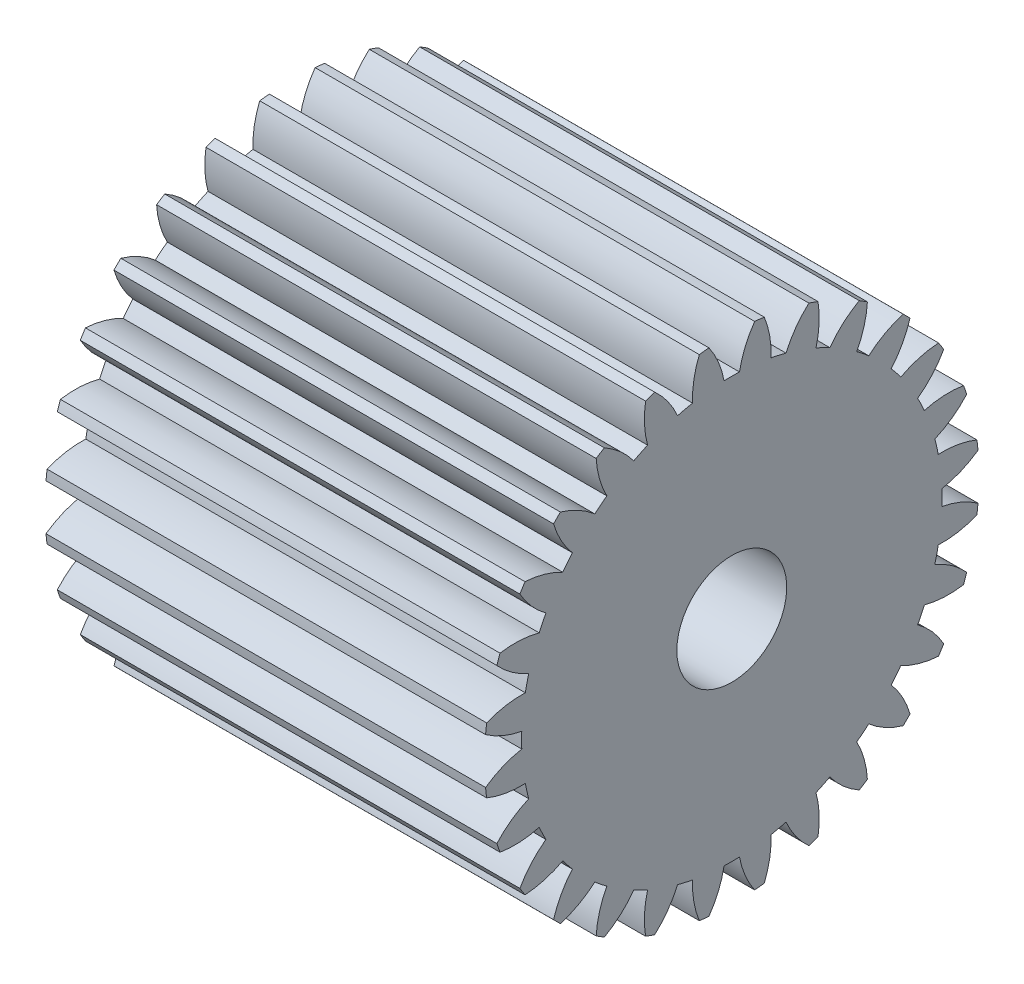
from build123d import *

# Parameters (mm, degrees)
BASPROSKE_W     = 40
BASPROSKE_H     = 22.5
TOOTHCUT_DEPTH  = 52.112620751
TEETHCUTS_COUNT = 28
TEETHCUTS_ANGLE = 347.142857143
BORSKE_R        = 5
BORE_DEPTH      = 50.0000508
SCALE1_SCALE    = 2


with BuildPart() as part:
    # BasProSke → Base-Revolve (revolve)
    with BuildSketch(Plane(origin=(0, 0, 0), x_dir=(1, 0, 0), z_dir=(0, 1, 0)), mode=Mode.PRIVATE) as base_revolve_sk:
        with Locations((20, 11.25)):
            Rectangle(BASPROSKE_W, BASPROSKE_H)
    revolve(base_revolve_sk.sketch.rotate(Axis((-10, 0, 0), (1, 0, 0)), 180), axis=Axis((-10, 0, 0), (1, 0, 0)))

    # TooCutSke → ToothCut (cut, through all)
    with BuildSketch(Plane(origin=(0, 0, 0), x_dir=(0, 0, -1), z_dir=(1, 0, 0))):
        with BuildLine():
            ThreePointArc((0.70071741, 19.111158288), (0, 19.124), (-0.70071741, 19.111158288))
            ThreePointArc((-0.70071741, 19.111158288), (-1.220048441, 20.845037035), (-2.098754998, 22.427413418))
            ThreePointArc((-2.098754998, 22.427413418), (0, 22.5254), (2.098754998, 22.427413418))
            ThreePointArc((2.098754998, 22.427413418), (1.220048441, 20.845037035), (0.70071741, 19.111158288))
        make_face()
    toothcut = extrude(amount=TOOTHCUT_DEPTH, mode=Mode.SUBTRACT)

    # TeethCuts: ToothCut ×28 about axis
    teethcuts_axis = Axis((-10, 0, 0), (1, 0, 0))
    for i in range(1, TEETHCUTS_COUNT):
        add(toothcut.rotate(teethcuts_axis, i * TEETHCUTS_ANGLE / (TEETHCUTS_COUNT - 1)), mode=Mode.SUBTRACT)

    # BorSke → Bore (cut, symmetric)
    with BuildSketch(Plane(origin=(0, 0, 0), x_dir=(0, 0, -1), z_dir=(1, 0, 0))):
        with Locations(Location((0, 0, 0), (0, 0, 180))):
            Circle(BORSKE_R)
    extrude(amount=BORE_DEPTH, both=True, mode=Mode.SUBTRACT)


with BuildPart() as part_1:
    # Scale1: scaled about (0, 0, 0)
    add(part.part.scale(SCALE1_SCALE))


solid = part_1.part
